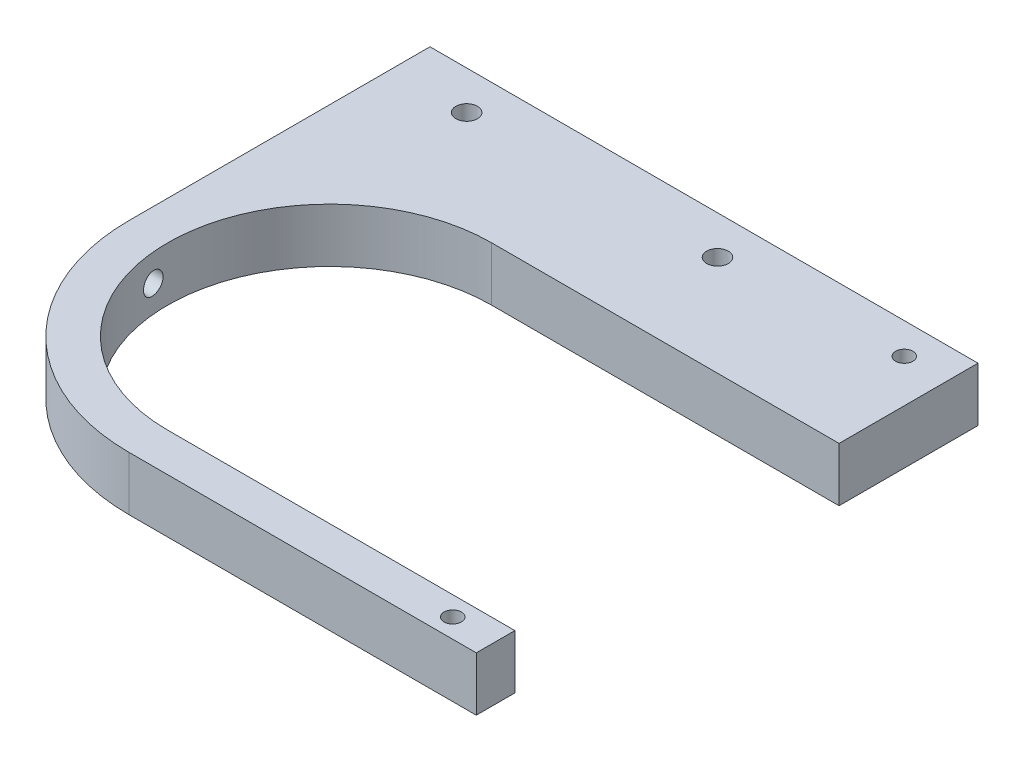
from build123d import *

# Parameters (mm, degrees)
EXTRUDE_1_DEPTH          = 7
SKETCH_2_R               = 1.125
CUT_EXTRUDE_2_DEPTH      = 1
CUT_EXTRUDE_2_DEPTH_BACK = 8
SKETCH_4_R               = 1.4
CUT_EXTRUDE_3_DEPTH      = 72
SKETCH_5_R               = 1.4
CUT_EXTRUDE_4_DEPTH      = 8.0000001


with BuildPart() as part:
    # 스케치1 → 보스-돌출1 (new body)
    with BuildSketch(Plane(origin=(0, 0, 0), x_dir=(1, 0, 0), z_dir=(0, 1, 0))):
        with BuildLine():
            Line((0, 21), (45, 21))
            Line((45, 21), (45, 39))
            Line((45, 39), (-26, 39))
            Line((-26, 39), (-26, 0))
            ThreePointArc((-26, 0), (-18.384776311, -18.384776311), (0, -26))
            Line((0, -26), (45, -26))
            Line((45, -26), (45, -21))
            Line((45, -21), (0, -21))
            ThreePointArc((0, -21), (-21, 0), (0, 21))
        make_face()
    extrude(amount=EXTRUDE_1_DEPTH)

    # 스케치2 → 컷-돌출2 (cut, two sides)
    with BuildSketch(Plane(origin=(0, 7, 0), x_dir=(1, 0, 0), z_dir=(0, 1, 0))) as cut_extrude_2_sk:
        with Locations((39.4457939, 35)):
            Circle(SKETCH_2_R)
        with Locations((39.4457939, -23.5)):
            Circle(SKETCH_2_R)
    extrude(amount=CUT_EXTRUDE_2_DEPTH, mode=Mode.SUBTRACT)
    extrude(cut_extrude_2_sk.sketch, amount=-CUT_EXTRUDE_2_DEPTH_BACK, mode=Mode.SUBTRACT)

    # 스케치4 → 컷-돌출3 (cut, through all)
    with BuildSketch(Plane.ZY.offset(26)):
        with Locations((1.986219712, 3.5)):
            Circle(SKETCH_4_R)
    extrude(amount=-CUT_EXTRUDE_3_DEPTH, mode=Mode.SUBTRACT)

    # 스케치5 → 컷-돌출4 (cut, through all)
    with BuildSketch(Plane(origin=(0, 7, 0), x_dir=(1, 0, 0), z_dir=(0, 1, 0))):
        with Locations((16.25, 34)):
            Circle(SKETCH_5_R)
        with Locations((-16.25, 34)):
            Circle(SKETCH_5_R)
    extrude(amount=-CUT_EXTRUDE_4_DEPTH, mode=Mode.SUBTRACT)


solid = part.part
